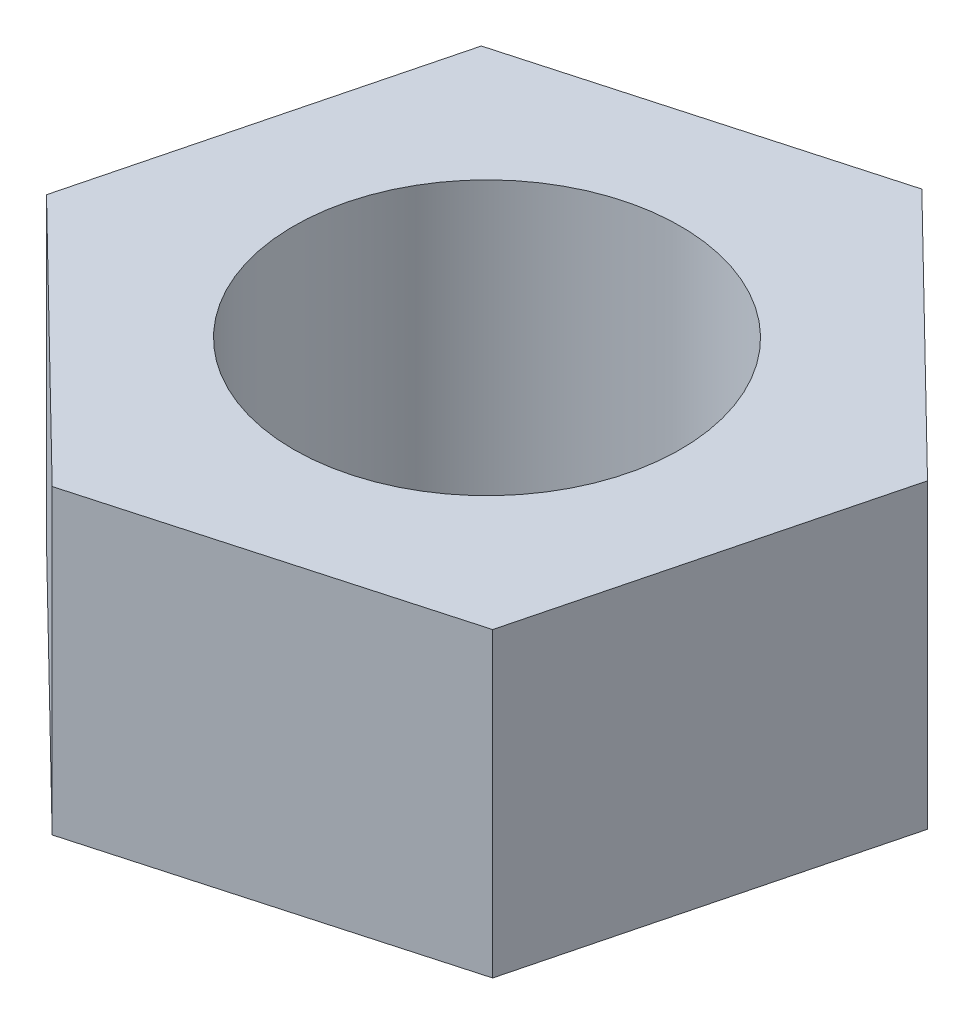
from build123d import *

# Parameters (mm, degrees)
SKETCH_1_R      = 2.5
EXTRUDE_1_DEPTH = 3.9


with BuildPart() as part:
    # 草图1 → 凸台-拉伸1 (new body)
    with BuildSketch(Plane(origin=(0, 0, 0), x_dir=(1, 0, 0), z_dir=(0, 1, 0))):
        Polygon((3.302474343, -3.229086024), (4.447707699, 1.245483664), (1.145233356, 4.474569688), (-3.302474343, 3.229086024), (-4.447707699, -1.245483664), (-1.145233356, -4.474569688), align=None)
        Circle(SKETCH_1_R, mode=Mode.SUBTRACT)
    extrude(amount=EXTRUDE_1_DEPTH)


solid = part.part
